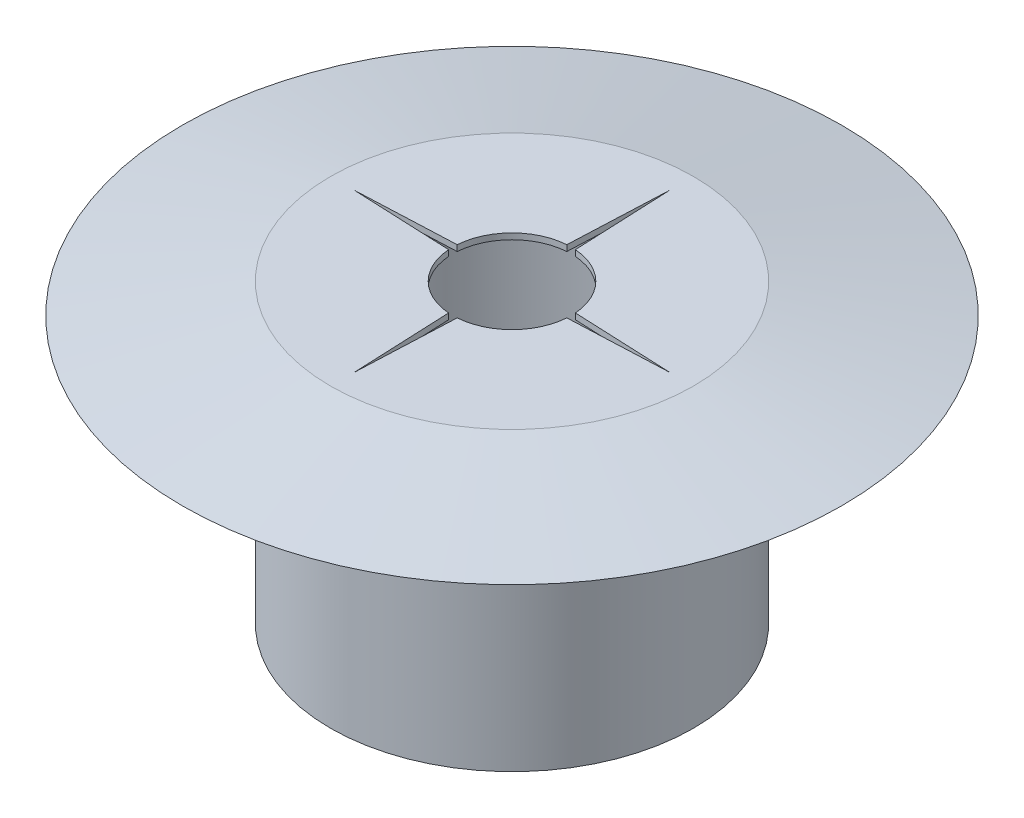
from build123d import *

# Parameters (mm, degrees)
SALIENTE_EXTRUIR2_DEPTH = 0.4


with BuildPart() as part:
    # Croquis1 → Revolución1 (revolve)
    with BuildSketch(Plane.XY):
        Polygon((-10.9, 20), (-10.9, 0), (-12.25, 0), (-12.25, 18), (-22.25, 18), (-12.25, 20), align=None)
    revolve(axis=Axis((0, 0, 0), (0, 1, 0)))

    # Croquis3 → Saliente-Extruir2 (add)
    with BuildSketch(Plane(origin=(0, 20, 0), x_dir=(1, 0, 0), z_dir=(0, 1, 0))):
        with BuildLine():
            ThreePointArc((10.9, 0), (7.707463915, -7.707463915), (0, -10.9))
            ThreePointArc((0, -10.9), (-7.707463915, -7.707463915), (-10.9, 0))
            ThreePointArc((-10.9, 0), (-7.707463915, 7.707463915), (0, 10.9))
            ThreePointArc((0, 10.9), (7.707463915, 7.707463915), (10.9, 0))
        make_face()
        with BuildLine():
            Line((0.290070904, -3.989468495), (0, -10.639817501))
            Line((0, -10.639817501), (-0.290070904, -3.989468495))
            ThreePointArc((-0.290070904, -3.989468495), (-2.828427125, -2.828427125), (-3.989468495, -0.290070904))
            Line((-3.989468495, -0.290070904), (-10.639817501, 0))
            Line((-10.639817501, 0), (-3.989468495, 0.290070904))
            ThreePointArc((-3.989468495, 0.290070904), (-2.828427125, 2.828427125), (-0.290070904, 3.989468495))
            Line((-0.290070904, 3.989468495), (0, 10.639817501))
            Line((0, 10.639817501), (0.290070904, 3.989468495))
            ThreePointArc((0.290070904, 3.989468495), (2.828427125, 2.828427125), (3.989468495, 0.290070904))
            Line((3.989468495, 0.290070904), (10.639817501, 0))
            Line((10.639817501, 0), (3.989468495, -0.290070904))
            ThreePointArc((3.989468495, -0.290070904), (2.828427125, -2.828427125), (0.290070904, -3.989468495))
        make_face(mode=Mode.SUBTRACT)
    extrude(amount=-SALIENTE_EXTRUIR2_DEPTH)


solid = part.part
